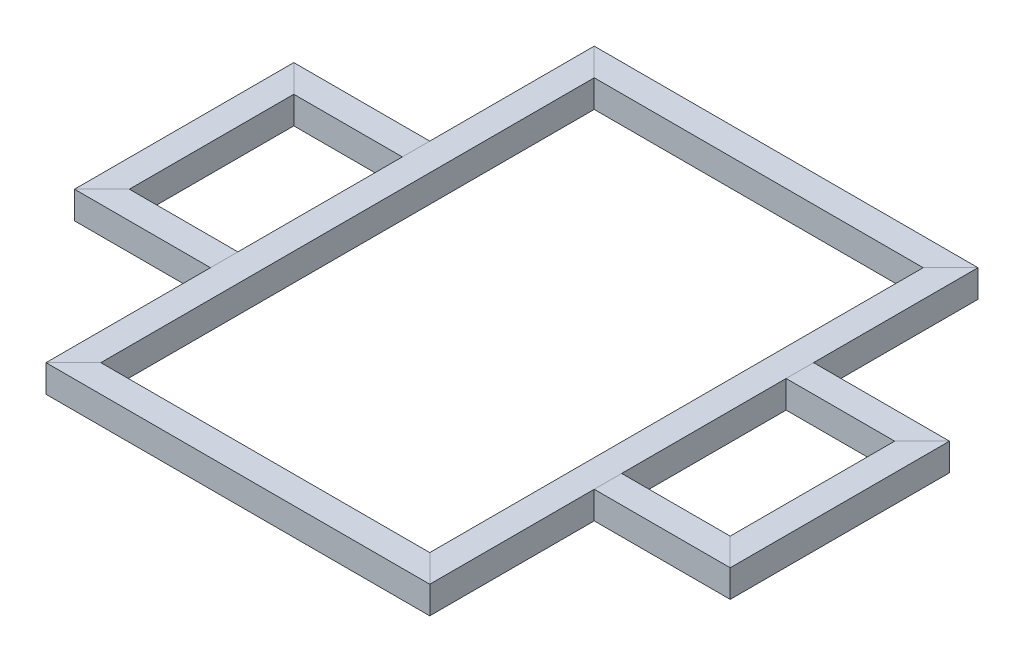
from build123d import *

# Parameters (mm, degrees)
SKETCH1_W             = 25
SKETCH1_H             = 25
SKETCH1_W_2           = 21
SKETCH1_H_2           = 21
BOSS_EXTRUDE1_DEPTH   = 250
BOSS_EXTRUDE1_2_DEPTH = 250
CUT_EXTRUDE1_DEPTH    = 26
SKETCH3_W             = 25
SKETCH3_H             = 25
SKETCH3_W_2           = 21
SKETCH3_H_2           = 21
BOSS_EXTRUDE2_DEPTH   = 175
BOSS_EXTRUDE2_2_DEPTH = 175
CUT_EXTRUDE2_DEPTH    = 26
SKETCH5_W             = 25
SKETCH5_H             = 25
SKETCH5_W_2           = 21
SKETCH5_H_2           = 21
BOSS_EXTRUDE3_DEPTH   = 124
BOSS_EXTRUDE3_2_DEPTH = 124
CUT_EXTRUDE3_DEPTH    = 26
SKETCH7_W             = 25
SKETCH7_H             = 25
SKETCH7_W_2           = 21
SKETCH7_H_2           = 21
BOSS_EXTRUDE4_DEPTH   = 100
CUT_EXTRUDE4_DEPTH    = 26


with BuildPart() as part:
    # Sketch1 → Boss-Extrude1 (new body, symmetric)
    with BuildSketch(Plane.XY):
        with Locations((-162.5, 0)):
            Rectangle(SKETCH1_W, SKETCH1_H)
        with Locations((-162.5, 0)):
            Rectangle(SKETCH1_W_2, SKETCH1_H_2, mode=Mode.SUBTRACT)
    extrude(amount=BOSS_EXTRUDE1_DEPTH, both=True)


with BuildPart() as body_2:
    # Sketch1 → Boss-Extrude1 2 (new body, symmetric)
    with BuildSketch(Plane.XY):
        with Locations((162.5, 0)):
            Rectangle(SKETCH1_W, SKETCH1_H)
        with Locations((162.5, 0)):
            Rectangle(SKETCH1_W_2, SKETCH1_H_2, mode=Mode.SUBTRACT)
    extrude(amount=BOSS_EXTRUDE1_2_DEPTH, both=True)


with BuildPart() as cut_extrude1_tool:
    # Sketch2 → Cut-Extrude1 (new body, through all)
    with BuildSketch(Plane(origin=(0, 12.5, 0), x_dir=(1, 0, 0), z_dir=(0, 1, 0))):
        Polygon((-175, 250), (-150, 225), (-150, 250), align=None)
        Polygon((175, 250), (150, 225), (150, 250), align=None)
        Polygon((-175, -250), (-150, -225), (-150, -250), align=None)
        Polygon((175, -250), (150, -225), (150, -250), align=None)
    extrude(amount=-CUT_EXTRUDE1_DEPTH)


with BuildPart() as part_1:
    add(part.part)

    # Cut-Extrude1: cut by cut_extrude1_tool
    add(cut_extrude1_tool.part, mode=Mode.SUBTRACT)


with BuildPart() as body_2_1:
    add(body_2.part)

    # Cut-Extrude1: cut by cut_extrude1_tool
    add(cut_extrude1_tool.part, mode=Mode.SUBTRACT)


with BuildPart() as body_3:
    # Sketch3 → Boss-Extrude2 (new body, symmetric)
    with BuildSketch(Plane(origin=(0, 0, 0), x_dir=(0, 0, -1), z_dir=(1, 0, 0))):
        with Locations((-237.5, 0)):
            Rectangle(SKETCH3_W, SKETCH3_H)
        with Locations((-237.5, 0)):
            Rectangle(SKETCH3_W_2, SKETCH3_H_2, mode=Mode.SUBTRACT)
    extrude(amount=BOSS_EXTRUDE2_DEPTH, both=True)


with BuildPart() as body_4:
    # Sketch3 → Boss-Extrude2 2 (new body, symmetric)
    with BuildSketch(Plane(origin=(0, 0, 0), x_dir=(0, 0, -1), z_dir=(1, 0, 0))):
        with Locations((237.5, 0)):
            Rectangle(SKETCH3_W, SKETCH3_H)
        with Locations((237.5, 0)):
            Rectangle(SKETCH3_W_2, SKETCH3_H_2, mode=Mode.SUBTRACT)
    extrude(amount=BOSS_EXTRUDE2_2_DEPTH, both=True)


with BuildPart() as cut_extrude2_tool:
    # Sketch4 → Cut-Extrude2 (new body, through all)
    with BuildSketch(Plane(origin=(0, 12.5, 0), x_dir=(1, 0, 0), z_dir=(0, 1, 0))):
        Polygon((-175, 250), (-175, 225), (-150, 225), align=None)
        Polygon((175, 250), (150, 225), (175, 225), align=None)
        Polygon((175, -225), (175, -250), (150, -225), align=None)
        Polygon((-150, -225), (-175, -250), (-175, -225), align=None)
    extrude(amount=-CUT_EXTRUDE2_DEPTH)


with BuildPart() as body_3_1:
    add(body_3.part)

    # Cut-Extrude2: cut by cut_extrude2_tool
    add(cut_extrude2_tool.part, mode=Mode.SUBTRACT)


with BuildPart() as body_4_1:
    add(body_4.part)

    # Cut-Extrude2: cut by cut_extrude2_tool
    add(cut_extrude2_tool.part, mode=Mode.SUBTRACT)


with BuildPart() as body_5:
    # Sketch5 → Boss-Extrude3 (new body)
    with BuildSketch(Plane.ZY.offset(175)):
        with Locations((-87.5, 0)):
            Rectangle(SKETCH5_W, SKETCH5_H)
        with Locations((-87.5, 0)):
            Rectangle(SKETCH5_W_2, SKETCH5_H_2, mode=Mode.SUBTRACT)
    extrude(amount=BOSS_EXTRUDE3_DEPTH)


with BuildPart() as body_6:
    # Sketch5 → Boss-Extrude3 2 (new body)
    with BuildSketch(Plane.ZY.offset(175)):
        with Locations((87.5, 0)):
            Rectangle(SKETCH5_W, SKETCH5_H)
        with Locations((87.5, 0)):
            Rectangle(SKETCH5_W_2, SKETCH5_H_2, mode=Mode.SUBTRACT)
    extrude(amount=BOSS_EXTRUDE3_2_DEPTH)


with BuildPart() as cut_extrude3_tool:
    # Sketch6 → Cut-Extrude3 (new body, through all)
    with BuildSketch(Plane(origin=(0, 12.5, 0), x_dir=(1, 0, 0), z_dir=(0, 1, 0))):
        Polygon((-299, 100), (-299, 75), (-274, 75), align=None)
        Polygon((-299, -100), (-299, -75), (-274, -75), align=None)
    extrude(amount=-CUT_EXTRUDE3_DEPTH)


with BuildPart() as body_5_1:
    add(body_5.part)

    # Cut-Extrude3: cut by cut_extrude3_tool
    add(cut_extrude3_tool.part, mode=Mode.SUBTRACT)


with BuildPart() as body_6_1:
    add(body_6.part)

    # Cut-Extrude3: cut by cut_extrude3_tool
    add(cut_extrude3_tool.part, mode=Mode.SUBTRACT)


with BuildPart() as body_7:
    # Sketch7 → Boss-Extrude4 (new body, symmetric)
    with BuildSketch(Plane.XY):
        with Locations((-286.5, 0)):
            Rectangle(SKETCH7_W, SKETCH7_H)
        with Locations((-286.5, 0)):
            Rectangle(SKETCH7_W_2, SKETCH7_H_2, mode=Mode.SUBTRACT)
    extrude(amount=BOSS_EXTRUDE4_DEPTH, both=True)

    # Sketch8 → Cut-Extrude4 (cut, through all)
    with BuildSketch(Plane(origin=(0, 12.5, 0), x_dir=(1, 0, 0), z_dir=(0, 1, 0))):
        Polygon((-299, 100), (-274, 75), (-274, 100), align=None)
        Polygon((-274, -75), (-274, -100), (-299, -100), align=None)
    extrude(amount=-CUT_EXTRUDE4_DEPTH, mode=Mode.SUBTRACT)


with BuildPart() as body_8:
    # Mirror1: mirrored copy
    add(body_5_1.part.mirror(Plane(origin=(0, 0, 0), x_dir=(0, 0, 1), z_dir=(1, 0, 0))))


with BuildPart() as body_9:
    # Mirror1 2: mirrored copy
    add(body_7.part.mirror(Plane(origin=(0, 0, 0), x_dir=(0, 0, 1), z_dir=(1, 0, 0))))


with BuildPart() as body_10:
    # Mirror1 3: mirrored copy
    add(body_6_1.part.mirror(Plane(origin=(0, 0, 0), x_dir=(0, 0, 1), z_dir=(1, 0, 0))))


solid = Compound([part_1.part, body_2_1.part, body_3_1.part, body_4_1.part, body_5_1.part, body_6_1.part, body_7.part, body_8.part, body_9.part, body_10.part])
